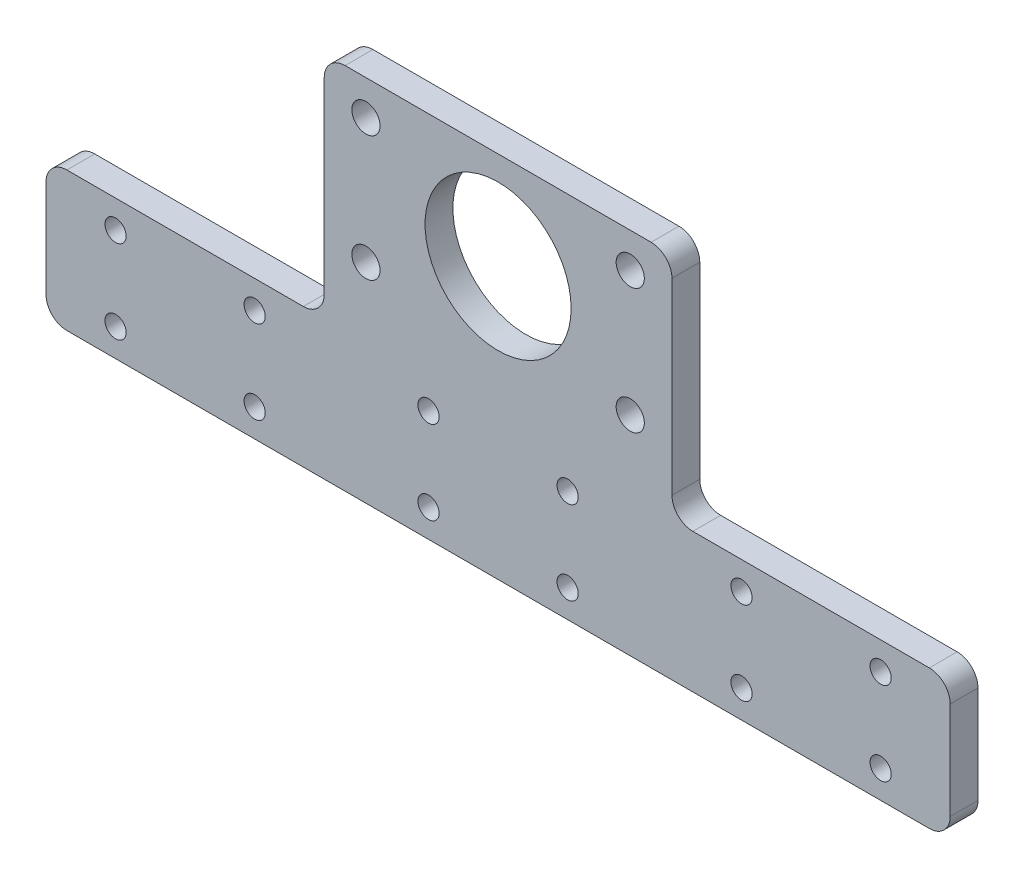
from build123d import *

# Parameters (mm, degrees)
EXTRUDE_1_DEPTH          = 2
FILLET_1_R               = 3
SKETCH_2_R               = 2.025
CUT_EXTRUDE_1_DEPTH      = 1
CUT_EXTRUDE_1_DEPTH_BACK = 5
SKETCH_3_R               = 1.525
CUT_EXTRUDE_2_DEPTH      = 10
SKETCH_4_R               = 10.5
CUT_EXTRUDE_3_DEPTH      = 5


with BuildPart() as part:
    # 草图1 → 凸台-拉伸1 (new body, symmetric)
    with BuildSketch(Plane.XY):
        Polygon((-25, 0), (25, 0), (25, -33), (65, -33), (65, -53), (-65, -53), (-65, -33), (-25, -33), align=None)
    extrude(amount=EXTRUDE_1_DEPTH, both=True)

    # 圆角1
    fillet_1_edges = [part.edges().sort_by_distance(p)[0] for p in [
        (-25, 0, 0),
        (25, 0, 0),
        (25, -33, 0),
        (65, -33, 0),
        (65, -53, 0),
        (-65, -53, 0),
        (-65, -33, 0),
        (-25, -33, 0),
    ]]
    fillet(fillet_1_edges, radius=FILLET_1_R)

    # 草图2 → 切除-拉伸1 (cut, two sides)
    with BuildSketch(Plane.XY.offset(2)) as cut_extrude_1_sk:
        with Locations((-19, -5)):
            Circle(SKETCH_2_R)
        with Locations((-19, -23)):
            Circle(SKETCH_2_R)
        with Locations((19, -5)):
            Circle(SKETCH_2_R)
        with Locations((19, -23)):
            Circle(SKETCH_2_R)
    extrude(amount=CUT_EXTRUDE_1_DEPTH, mode=Mode.SUBTRACT)
    extrude(cut_extrude_1_sk.sketch, amount=-CUT_EXTRUDE_1_DEPTH_BACK, mode=Mode.SUBTRACT)

    # 草图3 → 切除-拉伸2 (cut)
    with BuildSketch(Plane(origin=(0, 0, -2), x_dir=(-1, 0, 0), z_dir=(0, 0, -1))):
        with Locations((-55, -49)):
            Circle(SKETCH_3_R)
        with Locations((-35, -49)):
            Circle(SKETCH_3_R)
        with Locations((-10, -49)):
            Circle(SKETCH_3_R)
        with Locations((10, -49)):
            Circle(SKETCH_3_R)
        with Locations((35, -49)):
            Circle(SKETCH_3_R)
        with Locations((55, -49)):
            Circle(SKETCH_3_R)
        with Locations((55, -37)):
            Circle(SKETCH_3_R)
        with Locations((35, -37)):
            Circle(SKETCH_3_R)
        with Locations((10, -37)):
            Circle(SKETCH_3_R)
        with Locations((-10, -37)):
            Circle(SKETCH_3_R)
        with Locations((-35, -37)):
            Circle(SKETCH_3_R)
        with Locations((-55, -37)):
            Circle(SKETCH_3_R)
    extrude(amount=-CUT_EXTRUDE_2_DEPTH, mode=Mode.SUBTRACT)

    # 草图4 → 切除-拉伸3 (cut, through all)
    with BuildSketch(Plane.XY.offset(2)):
        with Locations((0, -14)):
            Circle(SKETCH_4_R)
    extrude(amount=-CUT_EXTRUDE_3_DEPTH, mode=Mode.SUBTRACT)


solid = part.part
